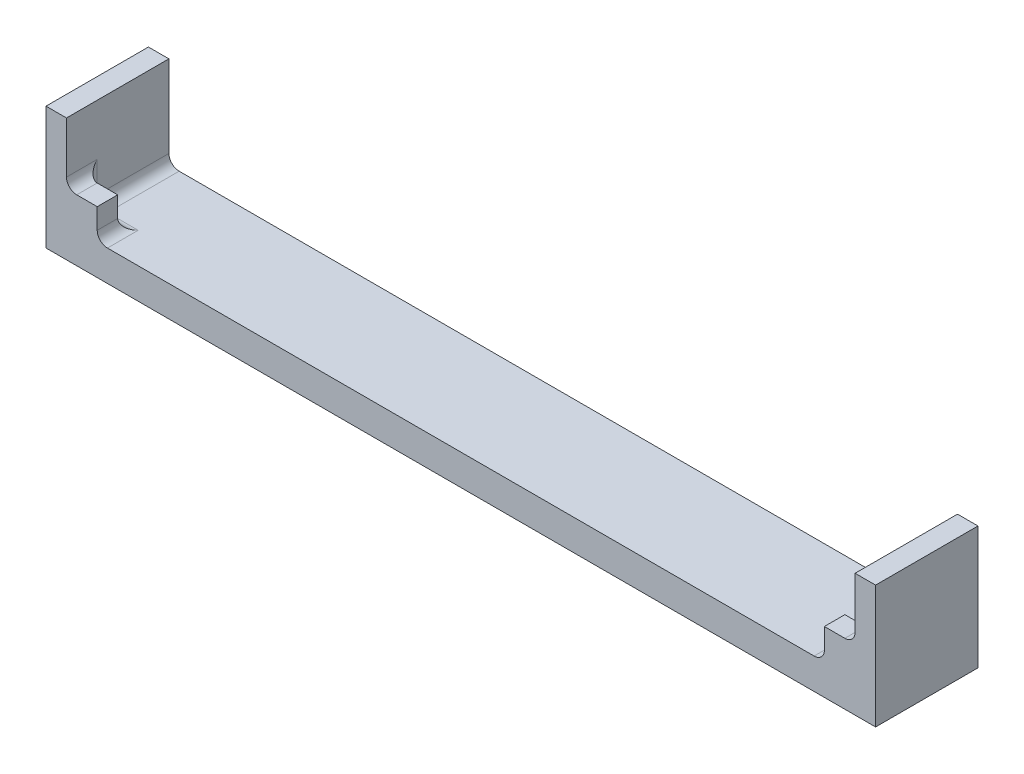
from build123d import *

# Parameters (mm, degrees)
SKETCH1_W           = 81
SKETCH1_H           = 10
BOSS_EXTRUDE1_DEPTH = 3
SKETCH2_W           = 2
SKETCH2_H           = 10
BOSS_EXTRUDE2_DEPTH = 9
SKETCH3_W           = 3
SKETCH3_H           = 3
BOSS_EXTRUDE3_DEPTH = 2
FILLET1_R           = 1
FILLET2_R           = 1


with BuildPart() as part:
    # Sketch1 → Boss-Extrude1 (new body)
    with BuildSketch(Plane(origin=(0, 0, 0), x_dir=(1, 0, 0), z_dir=(0, 1, 0))):
        with Locations((40.5, 5)):
            Rectangle(SKETCH1_W, SKETCH1_H)
    extrude(amount=BOSS_EXTRUDE1_DEPTH)

    # Sketch2 → Boss-Extrude2 (add)
    with BuildSketch(Plane(origin=(0, 3, 0), x_dir=(1, 0, 0), z_dir=(0, 1, 0))):
        with Locations((1, 5)):
            Rectangle(SKETCH2_W, SKETCH2_H)
        with Locations((80, 5)):
            Rectangle(SKETCH2_W, SKETCH2_H)
    extrude(amount=BOSS_EXTRUDE2_DEPTH)

    # Sketch3 → Boss-Extrude3 (add)
    with BuildSketch(Plane.XY):
        with Locations((3.5, 4.5)):
            Rectangle(SKETCH3_W, SKETCH3_H)
        with Locations((77.5, 4.5)):
            Rectangle(SKETCH3_W, SKETCH3_H)
    extrude(amount=-BOSS_EXTRUDE3_DEPTH)

    # Fillet1
    fillet1_edges = [part.edges().sort_by_distance(p)[0] for p in [
        (79, 3, -6),
        (2, 3, -6),
    ]]
    fillet(fillet1_edges, radius=FILLET1_R)

    # Fillet2
    fillet2_edges = [part.edges().sort_by_distance(p)[0] for p in [
        (2, 5, -2),
        (2, 6, -1),
        (5, 3, -1),
        (79, 6, -1),
        (77, 3, -2),
        (76, 3, -1),
        (4, 3, -2),
        (2.292893219, 3.292893219, -2),
        (79, 5, -2),
        (78.707106781, 3.292893219, -2),
    ]]
    fillet(fillet2_edges, radius=FILLET2_R)


solid = part.part
